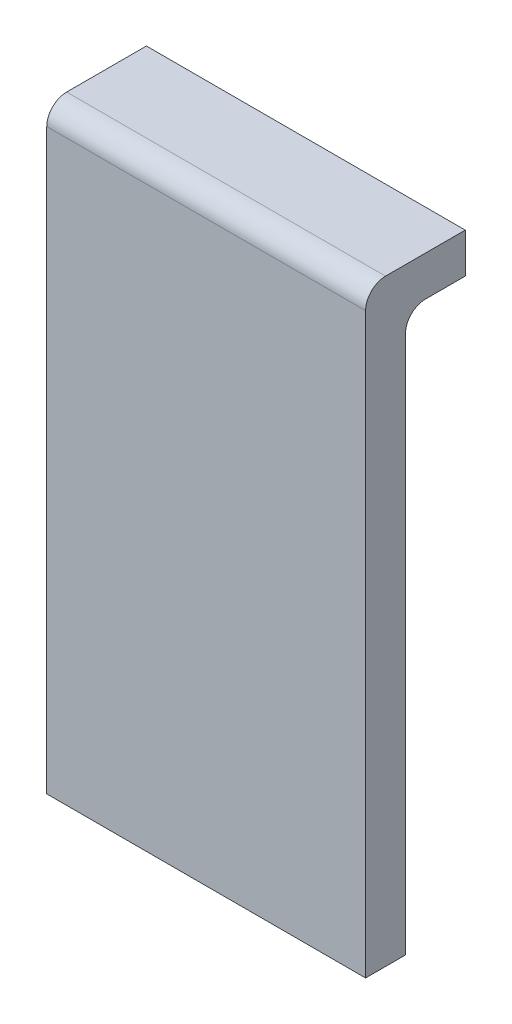
from build123d import *

# Parameters (mm, degrees)
ESQUISSE1_W        = 1.6
ESQUISSE1_H        = 3
BOSS_EXTRU_1_DEPTH = 0.2
ESQUISSE2_W        = 1.6
ESQUISSE2_H        = 0.2
BOSS_EXTRU_2_DEPTH = 0.3
CONG_1_R           = 0.1


with BuildPart() as part:
    # Esquisse1 → Boss.-Extru.1 (new body)
    with BuildSketch(Plane.XY):
        with Locations((0.8, 1.5)):
            Rectangle(ESQUISSE1_W, ESQUISSE1_H)
    extrude(amount=-BOSS_EXTRU_1_DEPTH)

    # Esquisse2 → Boss.-Extru.2 (add)
    with BuildSketch(Plane(origin=(0, 0, -0.2), x_dir=(-1, 0, 0), z_dir=(0, 0, -1))):
        with Locations((-0.8, 2.9)):
            Rectangle(ESQUISSE2_W, ESQUISSE2_H)
    extrude(amount=BOSS_EXTRU_2_DEPTH)

    # Congé1
    cong_1_edges = [part.edges().sort_by_distance(p)[0] for p in [
        (0.8, 3, 0),
        (0.8, 2.8, -0.2),
    ]]
    fillet(cong_1_edges, radius=CONG_1_R)


solid = part.part
